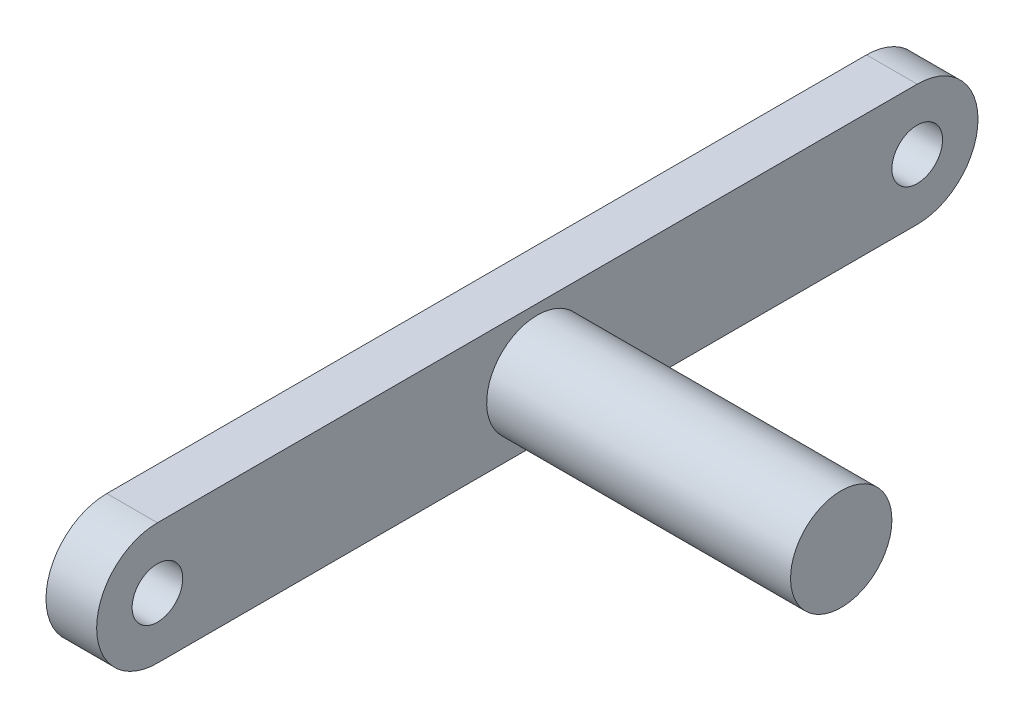
from build123d import *

# Parameters (mm, degrees)
ESBO_O1_W                = 30
ESBO_O1_H                = 5
ESBO_O2_R                = 2.5
RESSALTO_EXTRUS_O1_DEPTH = 5


with BuildPart() as part:
    # Esboço1 → Revolução1 (revolve)
    with BuildSketch(Plane.XY):
        with Locations((15, 2.5)):
            Rectangle(ESBO_O1_W, ESBO_O1_H)
    revolve(axis=Axis((30, 0, 0), (-1, 0, 0)))

    # Esboço2 → Ressalto-extrusão1 (add)
    with BuildSketch(Plane(origin=(0, 0, 0), x_dir=(0, 0, -1), z_dir=(1, 0, 0))):
        with BuildLine():
            Line((-37.5, 6), (37.5, 6))
            ThreePointArc((37.5, 6), (43.5, 0), (37.5, -6))
            Line((37.5, -6), (-37.5, -6))
            ThreePointArc((-37.5, -6), (-43.5, 0), (-37.5, 6))
        make_face()
        with Locations((-37.5, 0)):
            Circle(ESBO_O2_R, mode=Mode.SUBTRACT)
        with Locations((37.5, 0)):
            Circle(ESBO_O2_R, mode=Mode.SUBTRACT)
    extrude(amount=-RESSALTO_EXTRUS_O1_DEPTH)


solid = part.part
